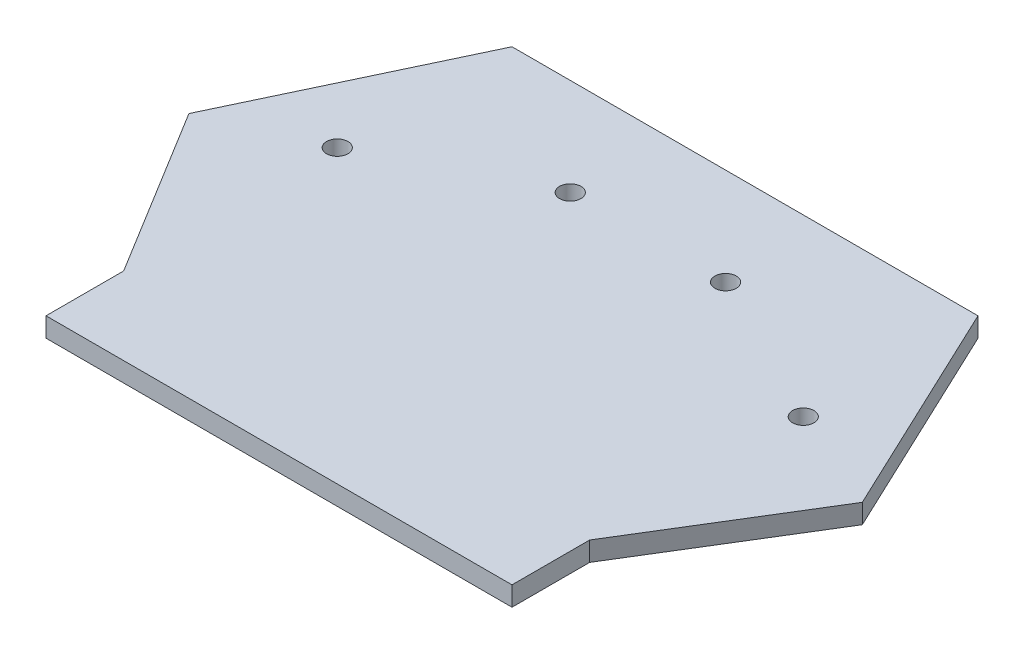
from build123d import *

# Parameters (mm, degrees)
SKETCH2_R           = 2.75
SKETCH2_W           = 60
SKETCH2_H           = 20
BOSS_EXTRUDE1_DEPTH = 5


with BuildPart() as part:
    # Sketch2 → Boss-Extrude1 (new body)
    with BuildSketch(Plane(origin=(0, 0, 0), x_dir=(1, 0, 0), z_dir=(0, 1, 0))):
        Polygon((-60, 30), (0, 30), (0, 130), (-20, 130), (-60, 130), (-86.701035329, 73.505676753), align=None)
        with Locations((-60, 85)):
            Circle(SKETCH2_R, mode=Mode.SUBTRACT)
        with Locations((-20, 105)):
            Circle(SKETCH2_R, mode=Mode.SUBTRACT)
        Polygon((0, 130), (0, 30), (60, 30), (86.701035329, 73.505676753), (60, 130), (20, 130), align=None)
        with Locations((60, 85)):
            Circle(SKETCH2_R, mode=Mode.SUBTRACT)
        with Locations((20, 105)):
            Circle(SKETCH2_R, mode=Mode.SUBTRACT)
        with Locations((-30, 20)):
            Rectangle(SKETCH2_W, SKETCH2_H)
        with Locations((30, 20)):
            Rectangle(SKETCH2_W, SKETCH2_H)
    extrude(amount=BOSS_EXTRUDE1_DEPTH)


solid = part.part
